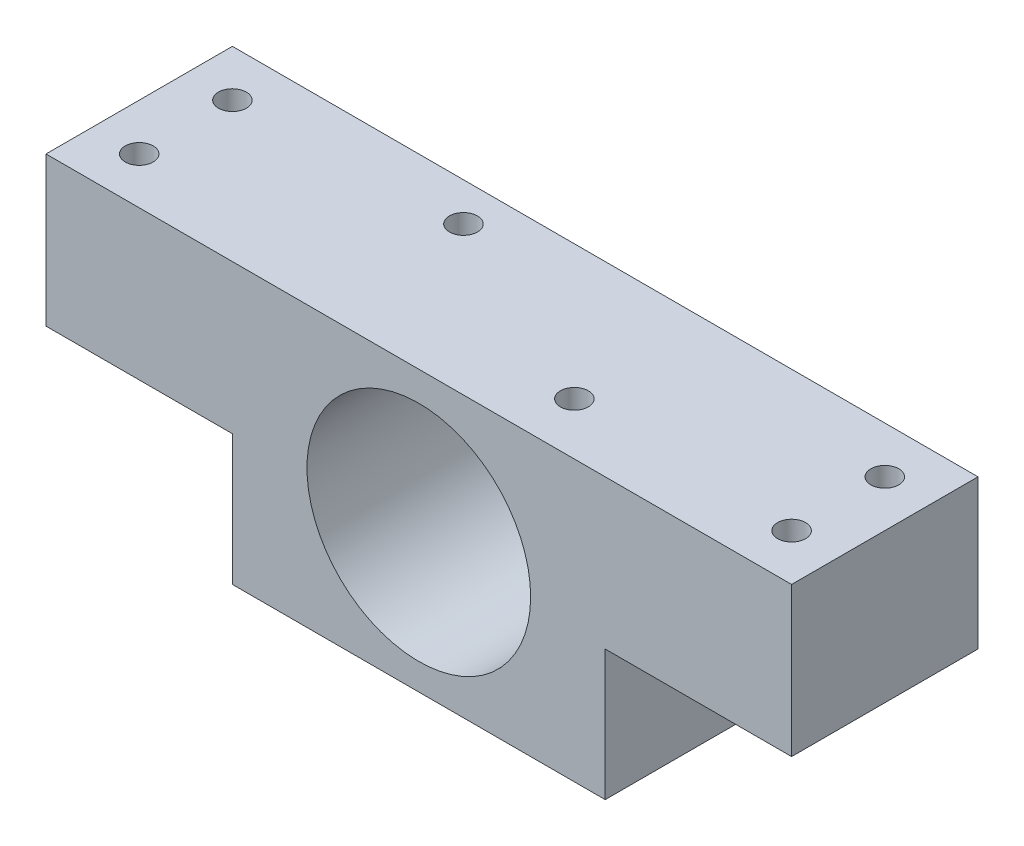
from build123d import *

# Parameters (mm, degrees)
SKETCH2_W           = 80
SKETCH2_H           = 20
BOSS_EXTRUDE1_DEPTH = 30
SKETCH3_W           = 20
SKETCH3_H           = 14
CUT_EXTRUDE1_DEPTH  = 30
SKETCH4_R           = 12
CUT_EXTRUDE2_DEPTH  = 30
SKETCH5_R           = 1.5
CUT_EXTRUDE3_DEPTH  = 30
SKETCH6_R           = 1.5
CUT_EXTRUDE4_DEPTH  = 3


with BuildPart() as part:
    # Sketch2 → Boss-Extrude1 (new body)
    with BuildSketch(Plane(origin=(0, 0, 0), x_dir=(1, 0, 0), z_dir=(0, 1, 0))):
        Rectangle(SKETCH2_W, SKETCH2_H)
    extrude(amount=BOSS_EXTRUDE1_DEPTH)

    # Sketch3 → Cut-Extrude1 (cut)
    with BuildSketch(Plane.XY.offset(10)):
        with Locations((30, 7)):
            Rectangle(SKETCH3_W, SKETCH3_H)
        with Locations((-30, 7)):
            Rectangle(SKETCH3_W, SKETCH3_H)
    extrude(amount=-CUT_EXTRUDE1_DEPTH, mode=Mode.SUBTRACT)

    # Sketch4 → Cut-Extrude2 (cut)
    with BuildSketch(Plane.XY.offset(10)):
        with Locations((0, 14.84)):
            Circle(SKETCH4_R)
    extrude(amount=-CUT_EXTRUDE2_DEPTH, mode=Mode.SUBTRACT)

    # Sketch5 → Cut-Extrude3 (cut)
    with BuildSketch(Plane(origin=(0, 30, 0), x_dir=(1, 0, 0), z_dir=(0, 1, 0))):
        with Locations((-35, 5)):
            Circle(SKETCH5_R)
        with Locations((-35, -5)):
            Circle(SKETCH5_R)
        with Locations((35, -5)):
            Circle(SKETCH5_R)
        with Locations((35, 5)):
            Circle(SKETCH5_R)
    extrude(amount=-CUT_EXTRUDE3_DEPTH, mode=Mode.SUBTRACT)

    # Sketch6 → Cut-Extrude4 (cut)
    with BuildSketch(Plane(origin=(0, 30, 0), x_dir=(1, 0, 0), z_dir=(0, 1, 0))):
        with Locations((-11.1, 5.89)):
            Circle(SKETCH6_R)
        with Locations((11.1, -4.41)):
            Circle(SKETCH6_R)
    extrude(amount=-CUT_EXTRUDE4_DEPTH, mode=Mode.SUBTRACT)


solid = part.part
